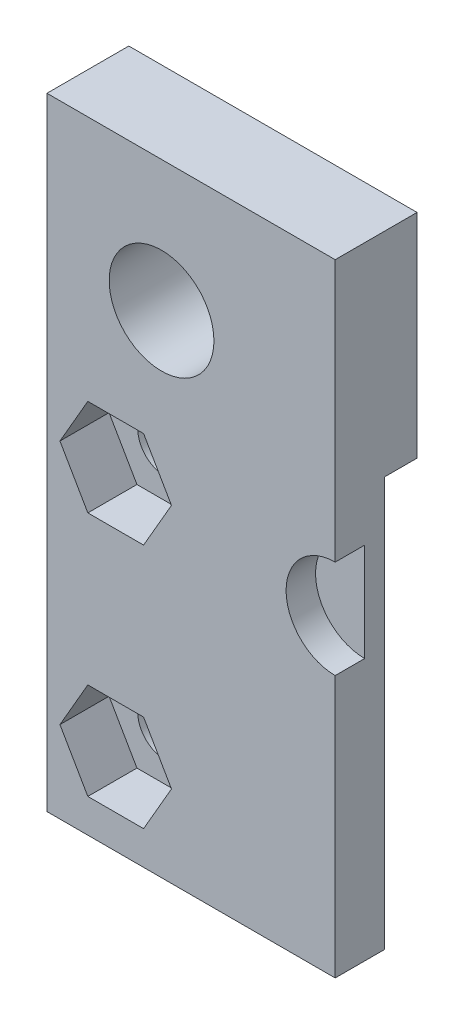
from build123d import *

# Parameters (mm, degrees)
SKETCH1_W           = 17.606601718
SKETCH1_H           = 38
SKETCH1_R           = 3.2
SKETCH1_R_2         = 1.65
BOSS_EXTRUDE1_DEPTH = 5
CUT_EXTRUDE4_START  = -5
SKETCH4_6_W         = 4
SKETCH4_6_H         = 25
CUT_EXTRUDE4_DEPTH  = 2
CUT_EXTRUDE1_DEPTH  = 3
CUT_EXTRUDE5_DEPTH  = 1.8


with BuildPart() as part:
    # Sketch1 → Boss-Extrude1 (new body)
    with BuildSketch(Plane.XY):
        with Locations((-0.607278146, -5.166340893)):
            Rectangle(SKETCH1_W, SKETCH1_H)
        with Locations((-2.410579005, 5.833659107)):
            Circle(SKETCH1_R, mode=Mode.SUBTRACT)
        with Locations((-5.210579005, -4.166340893)):
            Circle(SKETCH1_R_2, mode=Mode.SUBTRACT)
        with Locations((-5.210579005, -19.166340893)):
            Circle(SKETCH1_R_2, mode=Mode.SUBTRACT)
    extrude(amount=BOSS_EXTRUDE1_DEPTH)

    # Sketch4_6 → Cut-Extrude4 (cut)
    with BuildSketch(Plane.XY.offset(5).offset(CUT_EXTRUDE4_START)):
        with Locations((6.196022713, -11.666340893)):
            Rectangle(SKETCH4_6_W, SKETCH4_6_H)
    extrude(amount=CUT_EXTRUDE4_DEPTH, mode=Mode.SUBTRACT)

    # Sketch4 → Cut-Extrude1 (cut)
    with BuildSketch(Plane.XY.offset(5)):
        Polygon((-3.50739571, -1.216340893), (-6.913762299, -1.216340893), (-8.616945593, -4.166340893), (-6.913762299, -7.116340893), (-3.50739571, -7.116340893), (-1.804212416, -4.166340893), align=None)
        Polygon((-1.804212416, -19.166340893), (-3.50739571, -22.116340893), (-6.913762299, -22.116340893), (-8.616945593, -19.166340893), (-6.913762299, -16.216340893), (-3.50739571, -16.216340893), align=None)
    extrude(amount=-CUT_EXTRUDE1_DEPTH, mode=Mode.SUBTRACT)

    # Sketch4_7 → Cut-Extrude5 (cut)
    with BuildSketch(Plane.XY.offset(5)):
        with BuildLine():
            Line((8.196022713, -2.166340893), (8.196022713, -8.166340893))
            ThreePointArc((8.196022713, -8.166340893), (5.196022713, -5.166340893), (8.196022713, -2.166340893))
        make_face()
    extrude(amount=-CUT_EXTRUDE5_DEPTH, mode=Mode.SUBTRACT)


solid = part.part
